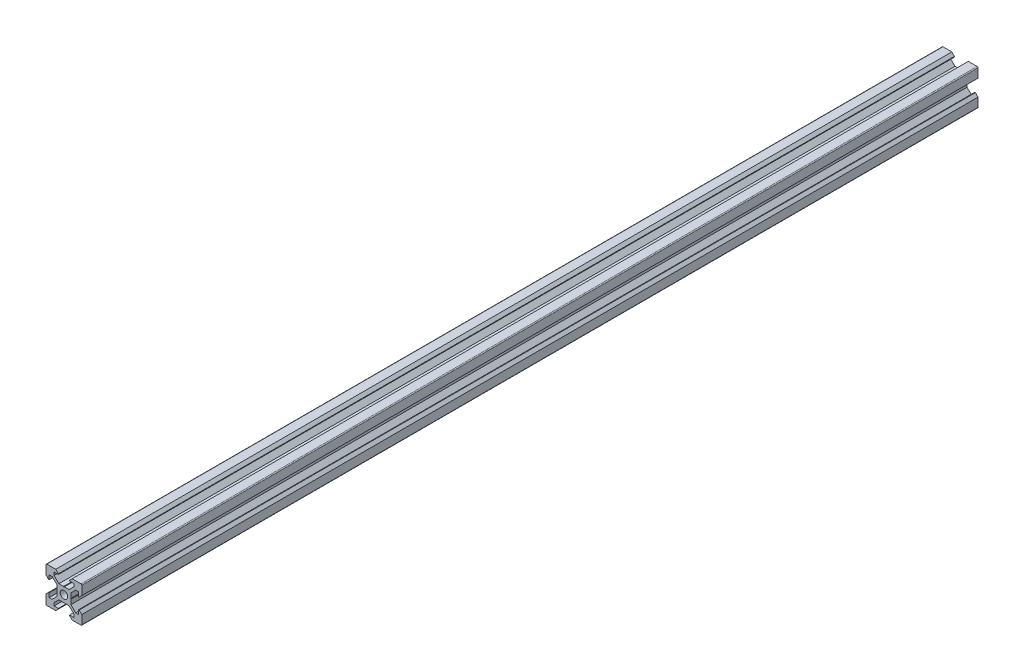
from build123d import *

# Parameters (mm, degrees)
SKETCH1_R           = 2.1
BOSS_EXTRUDE1_DEPTH = 500


with BuildPart() as part:
    # Sketch1 → Boss-Extrude1 (new body)
    with BuildSketch(Plane.XY):
        with BuildLine():
            Line((3.69, 0), (3.9, -0.21))
            Line((3.9, -0.21), (3.9, -2.839339828))
            Line((3.9, -2.839339828), (6.560660172, -5.5))
            Line((6.560660172, -5.5), (8.2, -5.5))
            Line((8.2, -5.5), (8.2, -3.125))
            Line((8.2, -3.125), (8.545, -3.125))
            Line((8.545, -3.125), (10, -4.58))
            Line((10, -4.58), (10, -9.5))
            ThreePointArc((10, -9.5), (9.853553391, -9.853553391), (9.5, -10))
            Line((9.5, -10), (4.58, -10))
            Line((4.58, -10), (3.125, -8.545))
            Line((3.125, -8.545), (3.125, -8.2))
            Line((3.125, -8.2), (5.5, -8.2))
            Line((5.5, -8.2), (5.5, -6.560660172))
            Line((5.5, -6.560660172), (2.839339828, -3.9))
            Line((2.839339828, -3.9), (0.21, -3.9))
            Line((0.21, -3.9), (0, -3.69))
            Line((0, -3.69), (-0.21, -3.9))
            Line((-0.21, -3.9), (-2.839339828, -3.9))
            Line((-2.839339828, -3.9), (-5.5, -6.560660172))
            Line((-5.5, -6.560660172), (-5.5, -8.2))
            Line((-5.5, -8.2), (-3.125, -8.2))
            Line((-3.125, -8.2), (-3.125, -8.545))
            Line((-3.125, -8.545), (-4.58, -10))
            Line((-4.58, -10), (-9.5, -10))
            ThreePointArc((-9.5, -10), (-9.853553391, -9.853553391), (-10, -9.5))
            Line((-10, -9.5), (-10, -4.58))
            Line((-10, -4.58), (-8.545, -3.125))
            Line((-8.545, -3.125), (-8.2, -3.125))
            Line((-8.2, -3.125), (-8.2, -5.5))
            Line((-8.2, -5.5), (-6.560660172, -5.5))
            Line((-6.560660172, -5.5), (-3.9, -2.839339828))
            Line((-3.9, -2.839339828), (-3.9, -0.21))
            Line((-3.9, -0.21), (-3.69, 0))
            Line((-3.69, 0), (-3.9, 0.21))
            Line((-3.9, 0.21), (-3.9, 2.839339828))
            Line((-3.9, 2.839339828), (-6.560660172, 5.5))
            Line((-6.560660172, 5.5), (-8.2, 5.5))
            Line((-8.2, 5.5), (-8.2, 3.125))
            Line((-8.2, 3.125), (-8.545, 3.125))
            Line((-8.545, 3.125), (-10, 4.58))
            Line((-10, 4.58), (-10, 9.5))
            ThreePointArc((-10, 9.5), (-9.853553391, 9.853553391), (-9.5, 10))
            Line((-9.5, 10), (-4.58, 10))
            Line((-4.58, 10), (-3.125, 8.545))
            Line((-3.125, 8.545), (-3.125, 8.2))
            Line((-3.125, 8.2), (-5.5, 8.2))
            Line((-5.5, 8.2), (-5.5, 6.560660172))
            Line((-5.5, 6.560660172), (-2.839339828, 3.9))
            Line((-2.839339828, 3.9), (-0.21, 3.9))
            Line((-0.21, 3.9), (0, 3.69))
            Line((0, 3.69), (0.21, 3.9))
            Line((0.21, 3.9), (2.839339828, 3.9))
            Line((2.839339828, 3.9), (5.5, 6.560660172))
            Line((5.5, 6.560660172), (5.5, 8.2))
            Line((5.5, 8.2), (3.125, 8.2))
            Line((3.125, 8.2), (3.125, 8.545))
            Line((3.125, 8.545), (4.58, 10))
            Line((4.58, 10), (9.5, 10))
            ThreePointArc((9.5, 10), (9.853553391, 9.853553391), (10, 9.5))
            Line((10, 9.5), (10, 4.58))
            Line((10, 4.58), (8.545, 3.125))
            Line((8.545, 3.125), (8.2, 3.125))
            Line((8.2, 3.125), (8.2, 5.5))
            Line((8.2, 5.5), (6.560660172, 5.5))
            Line((6.560660172, 5.5), (3.9, 2.839339828))
            Line((3.9, 2.839339828), (3.9, 0.21))
            Line((3.9, 0.21), (3.69, 0))
        make_face()
        Circle(SKETCH1_R, mode=Mode.SUBTRACT)
    extrude(amount=BOSS_EXTRUDE1_DEPTH)


solid = part.part
